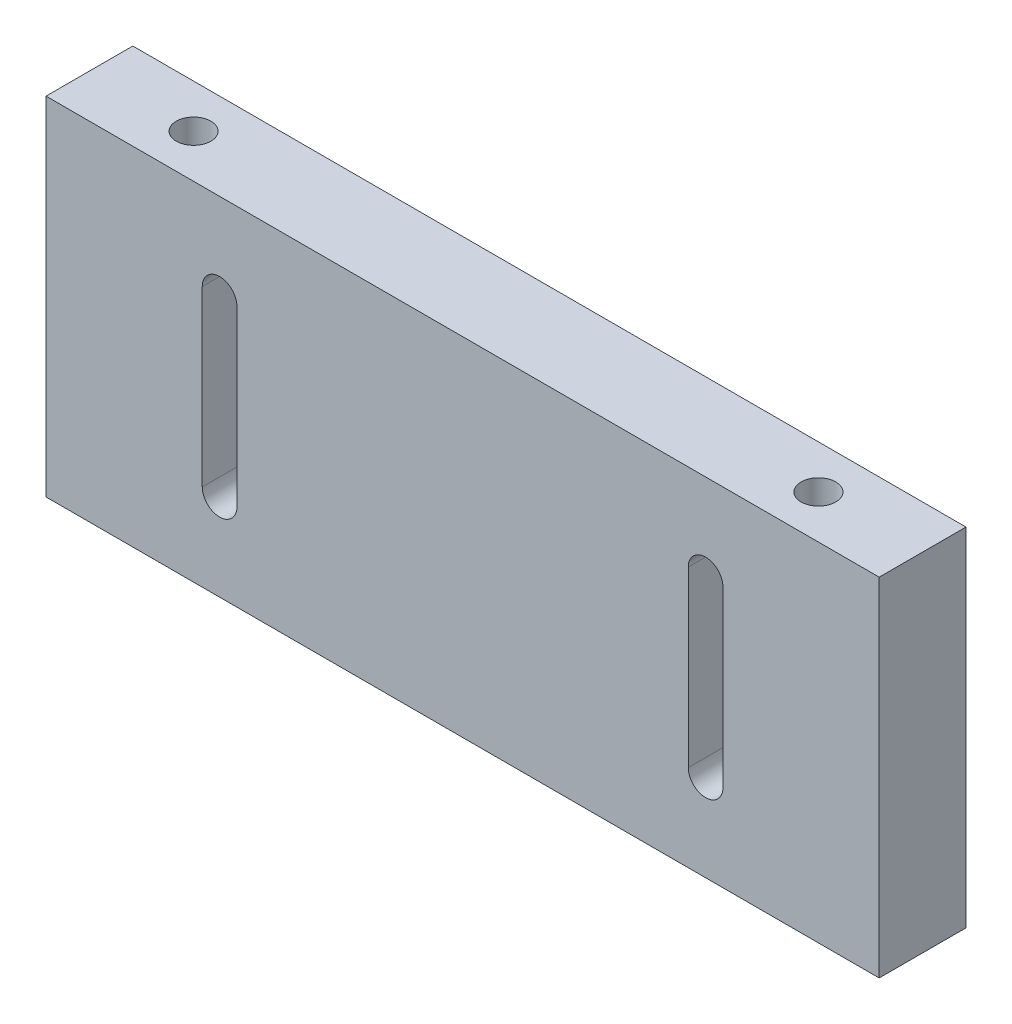
from build123d import *

# Parameters (mm, degrees)
CROQUIS1_W              = 240
CROQUIS1_H              = 25
SALIENTE_EXTRUIR1_DEPTH = 100
CROQUIS3_R              = 5
CORTAR_EXTRUIR1_DEPTH   = 25
CORTAR_EXTRUIR2_DEPTH   = 25


with BuildPart() as part:
    # Croquis1 → Saliente-Extruir1 (new body)
    with BuildSketch(Plane(origin=(0, 0, 0), x_dir=(1, 0, 0), z_dir=(0, 1, 0))):
        with Locations((0, -2.777777778)):
            Rectangle(CROQUIS1_W, CROQUIS1_H)
    extrude(amount=-SALIENTE_EXTRUIR1_DEPTH)

    # Croquis3 → Cortar-Extruir1 (cut)
    with BuildSketch(Plane(origin=(0, 0, 0), x_dir=(1, 0, 0), z_dir=(0, 1, 0))):
        with Locations((-90, -2.777777778)):
            Circle(CROQUIS3_R)
        with Locations((90, -2.777777778)):
            Circle(CROQUIS3_R)
    extrude(amount=-CORTAR_EXTRUIR1_DEPTH, mode=Mode.SUBTRACT)

    # Croquis4 → Cortar-Extruir2 (cut)
    with BuildSketch(Plane.XY.offset(15.277777778)):
        with BuildLine():
            Line((-75, -25), (-75, -75))
            ThreePointArc((-75, -75), (-70, -80), (-65, -75))
            Line((-65, -75), (-65, -25))
            ThreePointArc((-65, -25), (-70, -20), (-75, -25))
        make_face()
        with BuildLine():
            Line((65, -25), (65, -75))
            ThreePointArc((65, -75), (70, -80), (75, -75))
            Line((75, -75), (75, -25))
            ThreePointArc((75, -25), (70, -20), (65, -25))
        make_face()
    extrude(amount=-CORTAR_EXTRUIR2_DEPTH, mode=Mode.SUBTRACT)


solid = part.part
